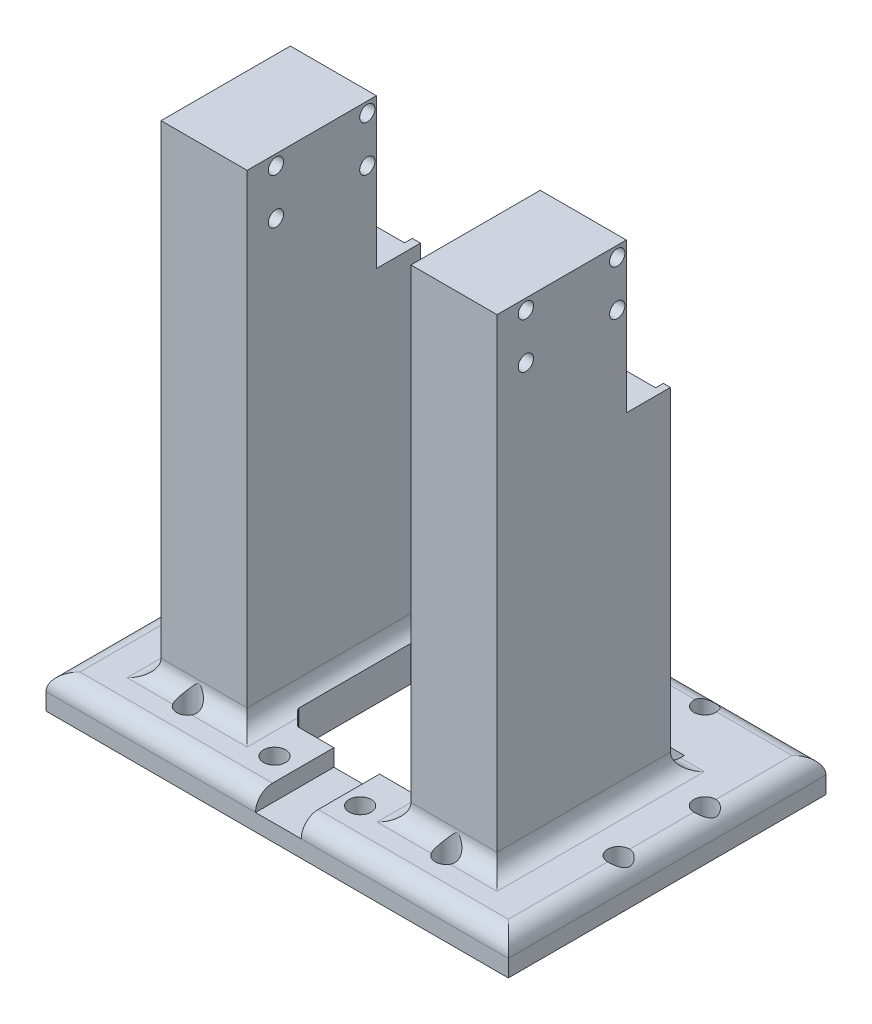
from build123d import *

# Parameters (mm, degrees)
BOSS_EXTRUDE1_DEPTH = 10
SKETCH2_W           = 25.382455423
SKETCH2_H           = 51.1096
SKETCH2_W_2         = 25.382455424
BOSS_EXTRUDE2_DEPTH = 142.23205499
SKETCH3_W           = 20.539655047
SKETCH3_H           = 123.846095538
CUT_EXTRUDE1_DEPTH  = 5.5
CUT_EXTRUDE2_START  = -7.5
SKETCH4_W           = 25.382455423
SKETCH4_H           = 46.86426915
CUT_EXTRUDE2_DEPTH  = 20
FILLET14_R          = 5
SKETCH5_R           = 1.6
CUT_EXTRUDE3_DEPTH  = 5
CUT_EXTRUDE4_DEPTH  = 153.23205499
SKETCH7_W           = 13.464106431
SKETCH7_H           = 23.097275307
CUT_EXTRUDE5_DEPTH  = 5
SKETCH8_R           = 3.25
SKETCH8_R_2         = 3.175
CUT_EXTRUDE6_DEPTH  = 153.23205499
SKETCH14_R          = 2.25
CUT_EXTRUDE7_DEPTH  = 118.834314686
SKETCH18_W          = 25.382455424
SKETCH18_H          = 44.127016755
CUT_EXTRUDE10_DEPTH = 41.060567495
SKETCH19_W          = 20.539655047
SKETCH19_H          = 13.385959452
CUT_EXTRUDE11_DEPTH = 5.5
SKETCH20_W          = 20.539655046
SKETCH20_H          = 13.385959452
CUT_EXTRUDE12_DEPTH = 5.5
SKETCH21_W          = 20.539655046
SKETCH21_H          = 93.105038235
SKETCH21_R          = 1.6
SKETCH21_W_2        = 20.539655047
BOSS_EXTRUDE3_DEPTH = 3.2069
SKETCH22_W          = 20.539655047
SKETCH22_H          = 8.486527729
CUT_EXTRUDE13_DEPTH = 16.0000001
SKETCH23_W          = 20.539655046
SKETCH23_H          = 8.486527729
CUT_EXTRUDE14_DEPTH = 16.0000001


with BuildPart() as part:
    # Sketch1 → Boss-Extrude1 (new body)
    with BuildSketch(Plane(origin=(4645.495048978, -5615.45116431, 222.286965694), x_dir=(1, 0, 0), z_dir=(0, 1, 0))):
        Polygon((-5.003976971, 249.919022988), (131.260480305, 249.919022988), (131.260480305, 156.290157663), (63.128251667, 156.290157663), (-5.003976971, 156.290157663), align=None)
    extrude(amount=BOSS_EXTRUDE1_DEPTH)

    # Sketch2 → Boss-Extrude2 (add)
    with BuildSketch(Plane(origin=(0, -5605.45116431, 0), x_dir=(1, 0, 0), z_dir=(0, 1, 0))):
        with Locations((4671.612442409, -24.983310101)):
            Rectangle(SKETCH2_W, SKETCH2_H)
        with Locations((4745.285596868, -24.983310101)):
            Rectangle(SKETCH2_W_2, SKETCH2_H)
    extrude(amount=BOSS_EXTRUDE2_DEPTH)

    # Sketch3 → Cut-Extrude1 (cut)
    with BuildSketch(Plane(origin=(0, 0, -0.571489899), x_dir=(-1, 0, 0), z_dir=(0, 0, -1))):
        with Locations((-4671.612442409, -5525.142157089)):
            Rectangle(SKETCH3_W, SKETCH3_H)
    cut_extrude1 = extrude(amount=-CUT_EXTRUDE1_DEPTH, mode=Mode.SUBTRACT)

    # Sketch4 → Cut-Extrude2 (cut)
    with BuildSketch(Plane(origin=(0, 0, 4.928510101), x_dir=(-1, 0, 0), z_dir=(0, 0, -1)).offset(CUT_EXTRUDE2_START)):
        with Locations((-4671.612442409, -5483.9139915)):
            Rectangle(SKETCH4_W, SKETCH4_H)
    cut_extrude2 = extrude(amount=CUT_EXTRUDE2_DEPTH, mode=Mode.SUBTRACT)

    # Fillet14
    fillet14_edges = [part.edges().sort_by_distance(p)[0] for p in [
        (4776.755529283, -5605.45116431, 19.182375368),
        (4658.921214697, -5605.45116431, 24.983310101),
        (4671.612442409, -5605.45116431, 50.538110101),
        (4684.30367012, -5605.45116431, 24.983310101),
        (4708.623300645, -5605.45116431, -27.632057294),
        (4671.612442409, -5605.45116431, -0.571489899),
        (4745.285596868, -5605.45116431, 50.538110101),
        (4757.97682458, -5605.45116431, 24.983310101),
        (4745.285596868, -5605.45116431, -0.571489899),
        (4732.594369156, -5605.45116431, 24.983310101),
        (4640.491072008, -5605.45116431, 19.182375368),
        (4708.623300645, -5605.45116431, 65.99680803),
    ]]
    fillet(fillet14_edges, radius=FILLET14_R)

    # Mirror1: Cut-Extrude1, Cut-Extrude2 across plane
    add(cut_extrude1.mirror(Plane.ZY.offset(-4708.623300645)), mode=Mode.SUBTRACT)
    add(cut_extrude2.mirror(Plane.ZY.offset(-4708.623300645)), mode=Mode.SUBTRACT)

    # Sketch5 → Cut-Extrude3 (cut)
    with BuildSketch(Plane(origin=(0, 0, 4.928510101), x_dir=(-1, 0, 0), z_dir=(0, 0, -1))):
        with Locations((-4671.842770313, -5574.737228853)):
            Circle(SKETCH5_R)
        with Locations((-4671.842770313, -5528.735999288)):
            Circle(SKETCH5_R)
        with Locations((-4745.017438635, -5574.737228853)):
            Circle(SKETCH5_R)
        with Locations((-4745.017438635, -5528.628482111)):
            Circle(SKETCH5_R)
    extrude(amount=-CUT_EXTRUDE3_DEPTH, mode=Mode.SUBTRACT)

    # Sketch6 → Cut-Extrude4 (cut, through all)
    with BuildSketch(Plane.XZ.offset(5615.45116431)):
        Polygon((4687.348070312, 38.150077354), (4687.348070312, 5.450659802), (4687.35442981, 5.323724065), (4687.372597929, 5.20226789), (4687.422135931, 5.02329467), (4687.444743306, 4.964651843), (4687.508601213, 4.832615857), (4687.571319699, 4.731484473), (4687.638876699, 4.641907758), (4687.7200447, 4.55263419), (4687.84495356, 4.42772533), (4691.137669473, 1.135009417), (4691.222399526, 1.051088855), (4691.251476138, 1.024546074), (4691.295529708, 0.987314905), (4691.359214955, 0.939150756), (4691.428077295, 0.893681536), (4691.523234947, 0.840680623), (4691.610896759, 0.796669555), (4691.843979056, 0.730334118), (4691.884577033, 0.722897964), (4692.093061536, 0.705668578), (4724.792479088, 0.705668578), (4724.936110559, 0.713816764), (4725.026777643, 0.727468199), (4725.101046112, 0.743724427), (4725.164345426, 0.761331135), (4725.264560971, 0.796669555), (4725.334243605, 0.827021022), (4725.395301554, 0.855819264), (4725.449934311, 0.878448893), (4725.496717591, 0.91881091), (4725.526325669, 0.939150756), (4729.165495924, 4.55263419), (4729.262148578, 4.661030049), (4729.298502432, 4.709125738), (4729.326565722, 4.749791118), (4729.346961215, 4.781631111), (4729.37122739, 4.822471683), (4729.397149732, 4.870380208), (4729.444119009, 4.957186745), (4729.461198306, 5.017169921), (4729.47550035, 5.058788106), (4729.495955769, 5.128598501), (4729.516316716, 5.198086482), (4729.519733382, 5.239148092), (4729.54334852, 5.450659802), (4729.537470312, 38.09014721), (4729.54334852, 38.150077354), (4729.534899388, 38.230845781), (4729.501521643, 38.477460317), (4729.37122739, 38.790523015), (4729.27532586, 38.922817446), (4729.17639288, 39.059293709), (4725.6905047, 42.52309419), (4725.551264329, 42.643471719), (4725.437264032, 42.728410325), (4725.125631636, 42.85749269), (4724.792479088, 42.909521887), (4692.174176963, 42.895068579), (4691.758430152, 42.864627364), (4691.454752306, 42.738839882), (4691.182501853, 42.536436032), (4687.7200447, 39.048102966), (4687.49735901, 38.790523015), (4687.372597929, 38.48932312), align=None)
    extrude(amount=-CUT_EXTRUDE4_DEPTH, mode=Mode.SUBTRACT)

    # Sketch7 → Cut-Extrude5 (cut)
    with BuildSketch(Plane(origin=(0, -5605.45116431, 0), x_dir=(1, 0, 0), z_dir=(0, 1, 0))):
        with Locations((4708.980933984, -54.448170377)):
            Rectangle(SKETCH7_W, SKETCH7_H)
    extrude(amount=-CUT_EXTRUDE5_DEPTH, mode=Mode.SUBTRACT)

    # Sketch8 → Cut-Extrude6 (cut, through all)
    with BuildSketch(Plane.XZ.offset(5615.45116431)):
        with Locations((4670.149923356, 53.863765694)):
            Circle(SKETCH8_R)
        with Locations((4746.349923356, 53.863765694)):
            Circle(SKETCH8_R)
        with Locations((4720.949923356, 53.863765694)):
            Circle(SKETCH8_R)
        with Locations((4670.149923356, -22.336234306)):
            Circle(SKETCH8_R)
        with Locations((4695.671922686, 53.814156415)):
            Circle(SKETCH8_R)
        with Locations((4695.549923356, -22.336234306)):
            Circle(SKETCH8_R)
        with Locations((4720.949923356, -22.336234306)):
            Circle(SKETCH8_R)
        with Locations((4746.349923356, -22.336234306)):
            Circle(SKETCH8_R_2)
        with Locations((4771.749923356, 28.463765694)):
            Circle(SKETCH8_R)
        with Locations((4771.749923356, 3.063765694)):
            Circle(SKETCH8_R)
        with Locations((4644.749923356, 3.063765694)):
            Circle(SKETCH8_R)
        with Locations((4644.749923356, 28.463765694)):
            Circle(SKETCH8_R)
    extrude(amount=-CUT_EXTRUDE6_DEPTH, mode=Mode.SUBTRACT)

    # Sketch14 → Cut-Extrude7 (cut, through all)
    with BuildSketch(Plane.ZY.offset(-4658.921214697)):
        with Locations((15.110858619, -5466.325470091)):
            Circle(SKETCH14_R)
        with Locations((15.110858619, -5479.725076471)):
            Circle(SKETCH14_R)
        with Locations((42.039251188, -5479.725076471)):
            Circle(SKETCH14_R)
        with Locations((42.039251188, -5466.325470091)):
            Circle(SKETCH14_R)
    extrude(amount=-CUT_EXTRUDE7_DEPTH, mode=Mode.SUBTRACT)

    # Sketch18 → Cut-Extrude10 (cut, through all)
    with BuildSketch(Plane(origin=(0, 0, 12.428510101), x_dir=(-1, 0, 0), z_dir=(0, 0, -1))):
        with Locations((-4745.285596868, -5485.282617697)):
            Rectangle(SKETCH18_W, SKETCH18_H)
    extrude(amount=CUT_EXTRUDE10_DEPTH, mode=Mode.SUBTRACT)

    # Sketch19 → Cut-Extrude11 (cut)
    with BuildSketch(Plane(origin=(0, 0, -0.571489899), x_dir=(-1, 0, 0), z_dir=(0, 0, -1))):
        with Locations((-4671.612442409, -5593.758184584)):
            Rectangle(SKETCH19_W, SKETCH19_H)
    extrude(amount=-CUT_EXTRUDE11_DEPTH, mode=Mode.SUBTRACT)

    # Sketch20 → Cut-Extrude12 (cut)
    with BuildSketch(Plane(origin=(0, 0, -0.571489899), x_dir=(-1, 0, 0), z_dir=(0, 0, -1))):
        with Locations((-4745.634158882, -5593.758184584)):
            Rectangle(SKETCH20_W, SKETCH20_H)
    extrude(amount=-CUT_EXTRUDE12_DEPTH, mode=Mode.SUBTRACT)

    # Sketch21 → Boss-Extrude3 (add)
    with BuildSketch(Plane(origin=(0, 0, 4.928510101), x_dir=(-1, 0, 0), z_dir=(0, 0, -1))):
        with Locations((-4745.634158882, -5553.898645193)):
            Rectangle(SKETCH21_W, SKETCH21_H)
        with Locations((-4745.017438635, -5574.737228853)):
            Circle(SKETCH21_R, mode=Mode.SUBTRACT)
        with Locations((-4745.017438635, -5528.628482111)):
            Circle(SKETCH21_R, mode=Mode.SUBTRACT)
        with Locations((-4671.612442409, -5553.898645193)):
            Rectangle(SKETCH21_W_2, SKETCH21_H)
        with Locations((-4671.842770313, -5574.737228853)):
            Circle(SKETCH21_R, mode=Mode.SUBTRACT)
        with Locations((-4671.842770313, -5528.735999288)):
            Circle(SKETCH21_R, mode=Mode.SUBTRACT)
    extrude(amount=BOSS_EXTRUDE3_DEPTH)

    # Sketch22 → Cut-Extrude13 (cut, through all)
    with BuildSketch(Plane(origin=(0, -5600.45116431, 0), x_dir=(1, 0, 0), z_dir=(0, 1, 0))):
        with Locations((4671.612442409, 2.521653763)):
            Rectangle(SKETCH22_W, SKETCH22_H)
    extrude(amount=-CUT_EXTRUDE13_DEPTH, mode=Mode.SUBTRACT)

    # Sketch23 → Cut-Extrude14 (cut, through all)
    with BuildSketch(Plane(origin=(0, -5600.45116431, 0), x_dir=(1, 0, 0), z_dir=(0, 1, 0))):
        with Locations((4745.634158882, 2.521653763)):
            Rectangle(SKETCH23_W, SKETCH23_H)
    extrude(amount=-CUT_EXTRUDE14_DEPTH, mode=Mode.SUBTRACT)


solid = part.part
